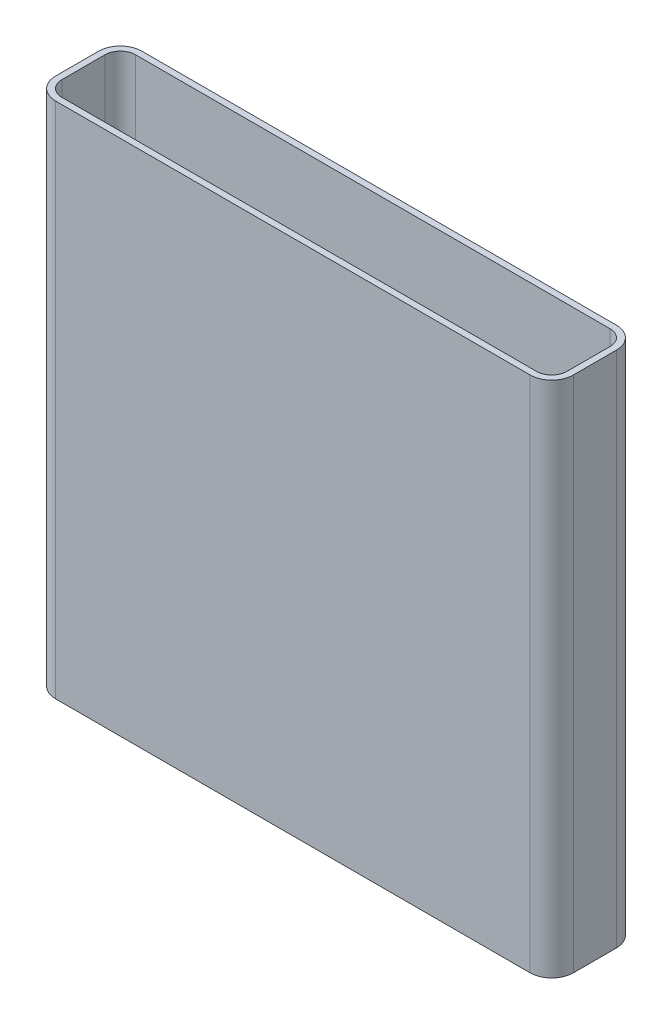
from build123d import *

# Parameters (mm, degrees)
EXTRUDE_THIN1_DEPTH = 1828.8


with BuildPart() as part:
    # Sketch1 → Extrude-Thin1 (new body)
    with BuildSketch(Plane(origin=(0, 0, 0), x_dir=(1, 0, 0), z_dir=(0, 1, 0))):
        with BuildLine():
            Line((-838.2, 152.4), (838.2, 152.4))
            ThreePointArc((838.2, 152.4), (892.081536726, 130.081536726), (914.4, 76.2))
            Line((914.4, 76.2), (914.4, -76.2))
            ThreePointArc((914.4, -76.2), (892.081536726, -130.081536726), (838.2, -152.4))
            Line((838.2, -152.4), (-838.2, -152.4))
            ThreePointArc((-838.2, -152.4), (-892.081536726, -130.081536726), (-914.4, -76.2))
            Line((-914.4, -76.2), (-914.4, 76.2))
            ThreePointArc((-914.4, 76.2), (-892.081536726, 130.081536726), (-838.2, 152.4))
        make_face()
        with BuildLine():
            Line((-838.2, 130.175), (838.2, 130.175))
            ThreePointArc((838.2, 130.175), (876.366088515, 114.366088515), (892.175, 76.2))
            Line((892.175, 76.2), (892.175, -76.2))
            ThreePointArc((892.175, -76.2), (876.366088515, -114.366088515), (838.2, -130.175))
            Line((838.2, -130.175), (-838.2, -130.175))
            ThreePointArc((-838.2, -130.175), (-876.366088515, -114.366088515), (-892.175, -76.2))
            Line((-892.175, -76.2), (-892.175, 76.2))
            ThreePointArc((-892.175, 76.2), (-876.366088515, 114.366088515), (-838.2, 130.175))
        make_face(mode=Mode.SUBTRACT)
    extrude(amount=EXTRUDE_THIN1_DEPTH)


solid = part.part
